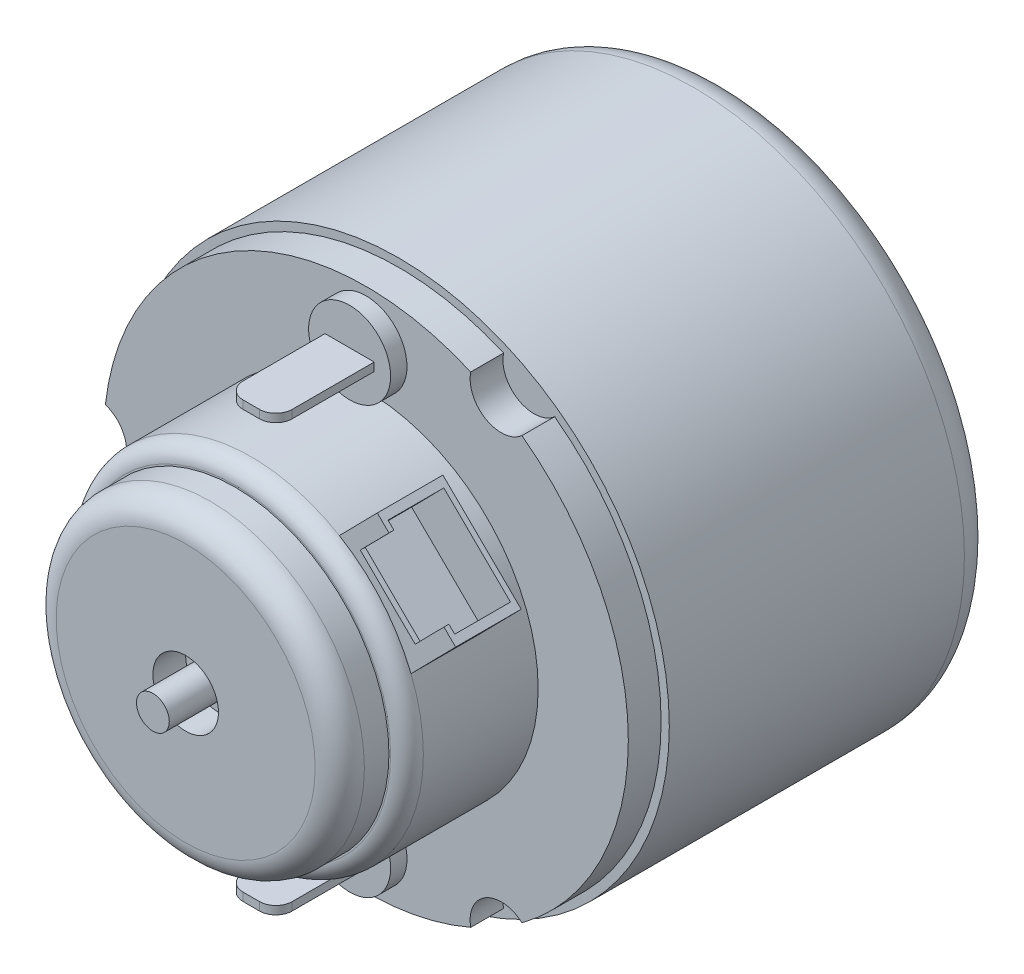
from build123d import *

# Parameters (mm, degrees)
ESBO_O1_R                        = 16.5
RESSALTO_EXTRUS_O1_DEPTH         = 20
ESBO_O4_R                        = 3.5
RESSALTO_EXTRUS_O4_DEPTH         = 1.5
ESBO_O14_R                       = 1
RESSALTO_EXTRUS_O7_DEPTH         = 4
FURO_ROSCADO_DE_M2_5X0_451_D     = 2.05
FURO_ROSCADO_DE_M2_5X0_451_DEPTH = 3.5
FURO_ROSCADO_DE_M2_5X0_451_TIP   = 0.615882135
FILETE1_R                        = 2
RESSALTO_EXTRUS_O9_DEPTH         = 2
ESBO_O18_R                       = 10.5
RESSALTO_EXTRUS_O10_DEPTH        = 8
FILETE2_R                        = 1
ESBO_O19_R                       = 9.4
RESSALTO_EXTRUS_O11_DEPTH        = 3
FILETE3_R                        = 1.5
ESBO_O20_R                       = 2
CORTE_EXTRUS_O1_DEPTH            = 2
ESBO_O21_R                       = 1
RESSALTO_EXTRUS_O13_DEPTH        = 4
ESBO_O22_R                       = 2.5
RESSALTO_EXTRUS_O15_DEPTH        = 1
RESSALTO_EXTRUS_O15_2_DEPTH      = 1
ESBO_O23_W                       = 3
ESBO_O23_H                       = 0.5
RESSALTO_EXTRUS_O16_DEPTH        = 6
FILETE4_R                        = 1
FILETE5_R                        = 1
RESSALTO_EXTRUS_O17_START        = -0.880532
ESBO_O24_W                       = 6.7
ESBO_O24_H                       = 4
RESSALTO_EXTRUS_O17_DEPTH        = 3.880532
ESBO_O25_W                       = 5.7
ESBO_O25_H                       = 3
ESBO_O25_H_2                     = 0.2
CORTE_EXTRUS_O2_DEPTH            = 2.8
ESBO_O26_W                       = 4.7
ESBO_O26_H                       = 0.3
CORTE_EXTRUS_O3_DEPTH            = 2.5


with BuildPart() as part:
    # Esboço1 → Ressalto-extrusão1 (new body)
    with BuildSketch(Plane.XY):
        Circle(ESBO_O1_R)
    extrude(amount=RESSALTO_EXTRUS_O1_DEPTH)

    # Esboço4 → Ressalto-extrusão4 (add)
    with BuildSketch(Plane(origin=(0, 0, 0), x_dir=(-1, 0, 0), z_dir=(0, 0, -1))):
        Circle(ESBO_O4_R)
    extrude(amount=RESSALTO_EXTRUS_O4_DEPTH)

    # Esboço14 → Ressalto-extrusão7 (add)
    with BuildSketch(Plane(origin=(0, 0, -1.5), x_dir=(-1, 0, 0), z_dir=(0, 0, -1))):
        Circle(ESBO_O14_R)
    extrude(amount=RESSALTO_EXTRUS_O7_DEPTH)

    # Furo roscado de M2.5x0.451
    with Locations(Plane(origin=(0, 0, 0), x_dir=(-1, 0, 0), z_dir=(0, 0, -1))):
        with Locations((11.258330249, -6.5), (0, 13), (-11.258330249, -6.5), (11.258330249, 6.5), (0, -13), (-11.258330249, 6.5)):
            Hole(FURO_ROSCADO_DE_M2_5X0_451_D / 2, depth=FURO_ROSCADO_DE_M2_5X0_451_DEPTH)
            with Locations((0, 0, -(FURO_ROSCADO_DE_M2_5X0_451_DEPTH + FURO_ROSCADO_DE_M2_5X0_451_TIP / 2))):  # 118° drill point
                Cone(0, FURO_ROSCADO_DE_M2_5X0_451_D / 2, FURO_ROSCADO_DE_M2_5X0_451_TIP, mode=Mode.SUBTRACT)

    # Filete1
    filete1_edges = [part.edges().sort_by_distance(p)[0] for p in [
        (-16.5, 0, 0),
    ]]
    fillet(filete1_edges, radius=FILETE1_R)

    # Esboço17 → Ressalto-extrusão9 (add)
    with BuildSketch(Plane.XY.offset(20)):
        with BuildLine():
            ThreePointArc((6.388366348, -14.669314074), (7.3, -12.643970895), (9.509815471, -12.867144583))
            ThreePointArc((9.509815471, -12.867144583), (16, 0), (9.509815471, 12.867144583))
            ThreePointArc((9.509815471, 12.867144583), (7.3, 12.643970895), (6.388366348, 14.669314074))
            ThreePointArc((6.388366348, 14.669314074), (-8, 13.856406461), (-15.898181818, 1.802169491))
            ThreePointArc((-15.898181818, 1.802169491), (-14.6, 0), (-15.898181818, -1.802169491))
            ThreePointArc((-15.898181818, -1.802169491), (-8, -13.856406461), (6.388366348, -14.669314074))
        make_face()
    extrude(amount=RESSALTO_EXTRUS_O9_DEPTH)

    # Esboço18 → Ressalto-extrusão10 (add)
    with BuildSketch(Plane.XY.offset(22)):
        Circle(ESBO_O18_R)
    extrude(amount=RESSALTO_EXTRUS_O10_DEPTH)

    # Filete2
    filete2_edges = [part.edges().sort_by_distance(p)[0] for p in [
        (-10.5, 0, 30),
    ]]
    fillet(filete2_edges, radius=FILETE2_R)

    # Esboço19 → Ressalto-extrusão11 (add)
    with BuildSketch(Plane.XY.offset(30)):
        Circle(ESBO_O19_R)
    extrude(amount=RESSALTO_EXTRUS_O11_DEPTH)

    # Filete3
    filete3_edges = [part.edges().sort_by_distance(p)[0] for p in [
        (-9.4, 0, 33),
    ]]
    fillet(filete3_edges, radius=FILETE3_R)

    # Esboço20 → Corte-extrusão1 (cut)
    with BuildSketch(Plane.XY.offset(33)):
        Circle(ESBO_O20_R)
    extrude(amount=-CORTE_EXTRUS_O1_DEPTH, mode=Mode.SUBTRACT)

    # Esboço21 → Ressalto-extrusão13 (add)
    with BuildSketch(Plane.XY.offset(31)):
        Circle(ESBO_O21_R)
    extrude(amount=RESSALTO_EXTRUS_O13_DEPTH)

    # Esboço24 → Ressalto-extrusão17 (add)
    with BuildSketch(Plane(origin=(7.361307949, 7.4873991, 0), x_dir=(-0.713085629, 0.701076947, 0), z_dir=(0.701076947, 0.713085629, 0)).offset(RESSALTO_EXTRUS_O17_START)):
        with Locations((-0.859017769, 27)):
            Rectangle(ESBO_O24_W, ESBO_O24_H)
    extrude(amount=RESSALTO_EXTRUS_O17_DEPTH)

    # Esboço25 → Corte-extrusão2 (cut)
    with BuildSketch(Plane(origin=(9.464538791, 9.626655986, 0), x_dir=(0.713085629, -0.701076947, 0), z_dir=(0.701076947, 0.713085629, 0))):
        with Locations((0.859017769, -27)):
            Rectangle(ESBO_O25_W, ESBO_O25_H)
        with Locations((0.859017769, -28.6)):
            Rectangle(ESBO_O25_W, ESBO_O25_H_2)
        with Locations((0.859017769, -25.4)):
            Rectangle(ESBO_O25_W, ESBO_O25_H_2)
    extrude(amount=-CORTE_EXTRUS_O2_DEPTH, mode=Mode.SUBTRACT)

    # Esboço26 → Corte-extrusão3 (cut)
    with BuildSketch(Plane(origin=(9.464538791, 9.626655986, 0), x_dir=(0.713085629, -0.701076947, 0), z_dir=(0.701076947, 0.713085629, 0))):
        with Locations((0.859017769, -28.85)):
            Rectangle(ESBO_O26_W, ESBO_O26_H)
    extrude(amount=-CORTE_EXTRUS_O3_DEPTH, mode=Mode.SUBTRACT)


with BuildPart() as body_2:
    # Esboço22 → Ressalto-extrusão15 (new body)
    with BuildSketch(Plane.XY.offset(22)):
        with Locations((0, 13)):
            Circle(ESBO_O22_R)
    extrude(amount=RESSALTO_EXTRUS_O15_DEPTH)



with BuildPart() as body_3:
    # Esboço22 → Ressalto-extrus_o15 2 (new body)
    with BuildSketch(Plane.XY.offset(22)):
        with Locations((0, -13)):
            Circle(ESBO_O22_R)
    extrude(amount=RESSALTO_EXTRUS_O15_2_DEPTH)


with BuildPart() as body_2_1:
    add(body_2.part)

    add(body_3.part)  # Ressalto-extrusão16 merges body 3
    # Esboço23 → Ressalto-extrusão16 (add)
    with BuildSketch(Plane.XY.offset(23)):
        with Locations((0, -13)):
            Rectangle(ESBO_O23_W, ESBO_O23_H)
        with Locations((0, 13)):
            Rectangle(ESBO_O23_W, ESBO_O23_H)
    extrude(amount=RESSALTO_EXTRUS_O16_DEPTH)

    # Filete4
    filete4_edges = [body_2_1.edges().sort_by_distance(p)[0] for p in [
        (-1.5, -13, 29),
        (1.5, -13, 29),
    ]]
    fillet(filete4_edges, radius=FILETE4_R)

    # Filete5
    filete5_edges = [body_2_1.edges().sort_by_distance(p)[0] for p in [
        (-1.5, 13, 29),
        (1.5, 13, 29),
    ]]
    fillet(filete5_edges, radius=FILETE5_R)


solid = Compound([part.part, body_2_1.part])
